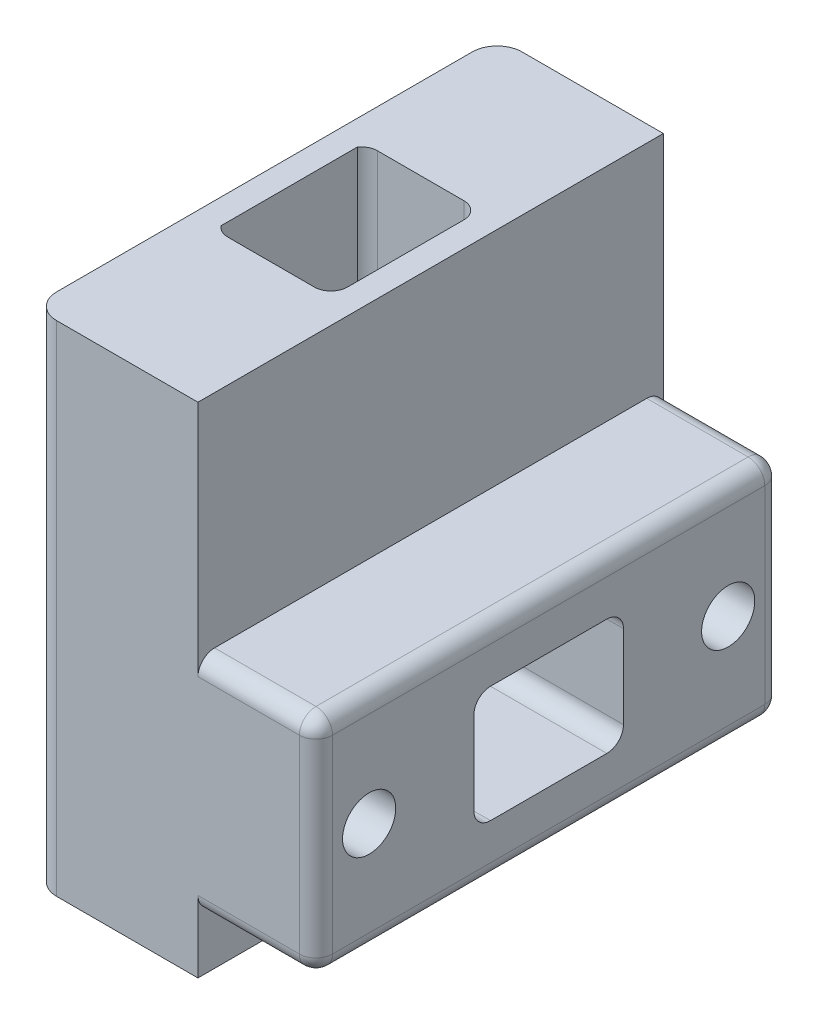
from build123d import *

# Parameters (mm, degrees)
EXTRUDE_1_DEPTH          = 28
SKETCH_2_R               = 1.6
CUT_EXTRUDE_1_DEPTH      = 1
CUT_EXTRUDE_1_DEPTH_BACK = 18.1
SKETCH_4_W               = 9
SKETCH_4_H               = 7
CUT_EXTRUDE_2_DEPTH      = 15.8
SKETCH_5_W               = 7
SKETCH_5_H               = 9
CUT_EXTRUDE_3_DEPTH      = 23
FILLET_1_R               = 1.5
FILLET_2_R               = 1
FILLET_3_R               = 1


with BuildPart() as part:
    # 草图1 → 凸台-拉伸1 (new body)
    with BuildSketch(Plane.XY):
        Polygon((0, 30), (0, 0), (10, 0), (10, 3.3), (17.1, 3.3), (17.1, 16.7), (10, 16.7), (10, 30), align=None)
    extrude(amount=EXTRUDE_1_DEPTH)

    # 草图2 → 切除-拉伸1 (cut, two sides)
    with BuildSketch(Plane(origin=(17.1, 0, 0), x_dir=(0, 0, -1), z_dir=(1, 0, 0))) as cut_extrude_1_sk:
        with Locations((-24.8, 10)):
            Circle(SKETCH_2_R)
        with Locations((-3.2, 10)):
            Circle(SKETCH_2_R)
    extrude(amount=CUT_EXTRUDE_1_DEPTH, mode=Mode.SUBTRACT)
    extrude(cut_extrude_1_sk.sketch, amount=-CUT_EXTRUDE_1_DEPTH_BACK, mode=Mode.SUBTRACT)

    # 草图4 → 切除-拉伸2 (cut)
    with BuildSketch(Plane(origin=(17.1, 0, 0), x_dir=(0, 0, -1), z_dir=(1, 0, 0))):
        with Locations((-14, 10)):
            Rectangle(SKETCH_4_W, SKETCH_4_H)
    extrude(amount=-CUT_EXTRUDE_2_DEPTH, mode=Mode.SUBTRACT)

    # 草图5 → 切除-拉伸3 (cut)
    with BuildSketch(Plane(origin=(0, 30, 0), x_dir=(1, 0, 0), z_dir=(0, 1, 0))):
        with Locations((5, -14)):
            Rectangle(SKETCH_5_W, SKETCH_5_H)
    extrude(amount=-CUT_EXTRUDE_3_DEPTH, mode=Mode.SUBTRACT)

    # 圆角1
    fillet_1_edges = [part.edges().sort_by_distance(p)[0] for p in [
        (0, 15, 0),
        (0, 15, 28),
    ]]
    fillet(fillet_1_edges, radius=FILLET_1_R)

    # 圆角2
    fillet_2_edges = [part.edges().sort_by_distance(p)[0] for p in [
        (8.5, 13.5, 14),
        (8.5, 21.75, 18.5),
        (8.5, 21.75, 9.5),
        (12.8, 13.5, 18.5),
        (12.8, 13.5, 9.5),
        (9.2, 6.5, 9.5),
        (9.2, 6.5, 18.5),
        (1.3, 6.5, 14),
        (1.3, 10, 18.5),
        (1.3, 10, 9.5),
    ]]
    fillet(fillet_2_edges, radius=FILLET_2_R)

    # 圆角3
    fillet_3_edges = [part.edges().sort_by_distance(p)[0] for p in [
        (17.1, 16.7, 14),
        (17.1, 3.3, 14),
        (13.55, 3.3, 28),
        (17.1, 10, 28),
        (13.55, 16.7, 28),
        (13.55, 16.7, 0),
        (17.1, 10, 0),
        (13.55, 3.3, 0),
    ]]
    fillet(fillet_3_edges, radius=FILLET_3_R)


solid = part.part
